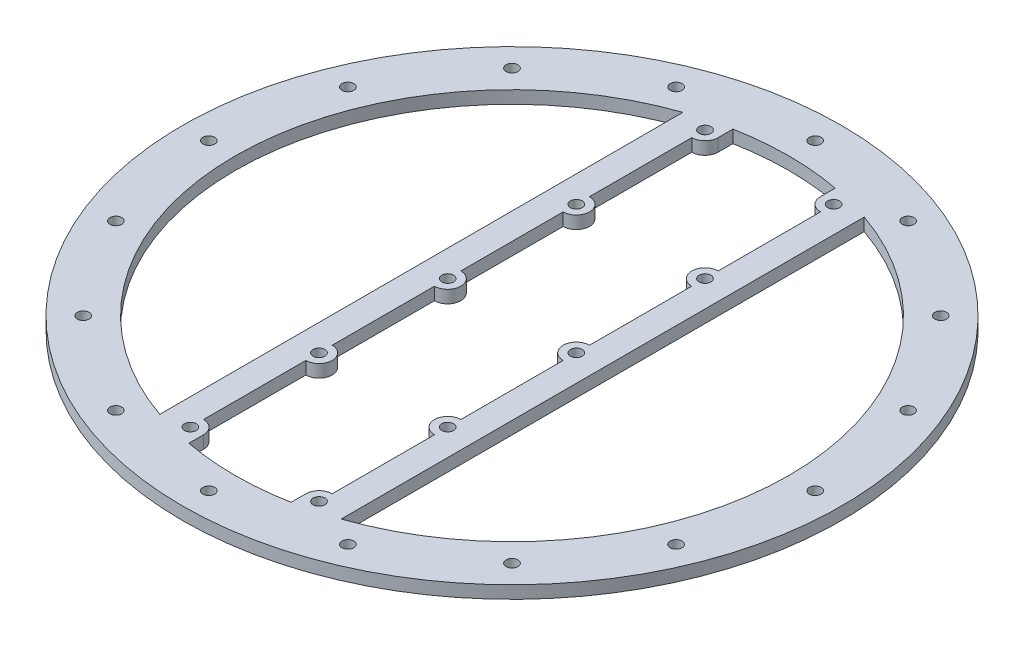
from build123d import *

# Parameters (mm, degrees)
SKETCH1_R           = 79.375
SKETCH1_R_2         = 66.675
SKETCH1_R_3         = 1.4224
BOSS_EXTRUDE1_DEPTH = 3.048
SKETCH2_R           = 1.4224
BOSS_EXTRUDE2_DEPTH = 3.048


with BuildPart() as part:
    # Sketch1 → Boss-Extrude1 (new body)
    with BuildSketch(Plane(origin=(0, 0, 0), x_dir=(1, 0, 0), z_dir=(0, 1, 0))):
        with Locations(Location((0, 0, 0), (0, 0, 90))):
            Circle(SKETCH1_R)
        with Locations(Location((0, 0, 0), (0, 0, 90))):
            Circle(SKETCH1_R_2, mode=Mode.SUBTRACT)
        with Locations(Location((0, 73.025, 0), (0, 0, 90))):
            Circle(SKETCH1_R_3, mode=Mode.SUBTRACT)
        with Locations(Location((27.945457648, 67.466302862, 0), (0, 0, 90))):
            Circle(SKETCH1_R_3, mode=Mode.SUBTRACT)
        with Locations(Location((51.636472696, 51.636472696, 0), (0, 0, 90))):
            Circle(SKETCH1_R_3, mode=Mode.SUBTRACT)
        with Locations(Location((67.466302862, 27.945457648, 0), (0, 0, 90))):
            Circle(SKETCH1_R_3, mode=Mode.SUBTRACT)
        with Locations(Location((73.025, 0, 0), (0, 0, 90))):
            Circle(SKETCH1_R_3, mode=Mode.SUBTRACT)
        with Locations(Location((67.466302862, -27.945457648, 0), (0, 0, 90))):
            Circle(SKETCH1_R_3, mode=Mode.SUBTRACT)
        with Locations(Location((51.636472696, -51.636472696, 0), (0, 0, 90))):
            Circle(SKETCH1_R_3, mode=Mode.SUBTRACT)
        with Locations(Location((27.945457648, -67.466302862, 0), (0, 0, 90))):
            Circle(SKETCH1_R_3, mode=Mode.SUBTRACT)
        with Locations(Location((0, -73.025, 0), (0, 0, 90))):
            Circle(SKETCH1_R_3, mode=Mode.SUBTRACT)
        with Locations(Location((-27.945457648, -67.466302862, 0), (0, 0, 90))):
            Circle(SKETCH1_R_3, mode=Mode.SUBTRACT)
        with Locations(Location((-51.636472696, -51.636472696, 0), (0, 0, 90))):
            Circle(SKETCH1_R_3, mode=Mode.SUBTRACT)
        with Locations(Location((-67.466302862, -27.945457648, 0), (0, 0, 90))):
            Circle(SKETCH1_R_3, mode=Mode.SUBTRACT)
        with Locations(Location((-73.025, 0, 0), (0, 0, 90))):
            Circle(SKETCH1_R_3, mode=Mode.SUBTRACT)
        with Locations(Location((-67.466302862, 27.945457648, 0), (0, 0, 90))):
            Circle(SKETCH1_R_3, mode=Mode.SUBTRACT)
        with Locations(Location((-51.636472696, 51.636472696, 0), (0, 0, 90))):
            Circle(SKETCH1_R_3, mode=Mode.SUBTRACT)
        with Locations(Location((-27.945457648, 67.466302862, 0), (0, 0, 90))):
            Circle(SKETCH1_R_3, mode=Mode.SUBTRACT)
    extrude(amount=BOSS_EXTRUDE1_DEPTH)

    # Sketch2 → Boss-Extrude2 (add)
    with BuildSketch(Plane(origin=(0, 3.048, 0), x_dir=(1, 0, 0), z_dir=(0, 1, 0))):
        with BuildLine():
            Line((-15.494, 3.175), (-15.494, 27.813))
            ThreePointArc((-15.494, 27.813), (-12.319, 30.988), (-15.494, 34.163))
            Line((-15.494, 34.163), (-15.494, 58.801))
            ThreePointArc((-15.494, 58.801), (-13.24893597, 59.73093597), (-12.319, 61.976))
            Line((-12.319, 61.976), (-12.319, 65.527077334))
            ThreePointArc((-12.319, 65.527077334), (-17.128346163, 64.437375666), (-21.844, 62.995200524))
            Line((-21.844, 62.995200524), (-21.844, -62.995200524))
            ThreePointArc((-21.844, -62.995200524), (-17.128346163, -64.437375666), (-12.319, -65.527077334))
            Line((-12.319, -65.527077334), (-12.319, -61.976))
            ThreePointArc((-12.319, -61.976), (-13.24893597, -59.73093597), (-15.494, -58.801))
            Line((-15.494, -58.801), (-15.494, -34.163))
            ThreePointArc((-15.494, -34.163), (-12.319, -30.988), (-15.494, -27.813))
            Line((-15.494, -27.813), (-15.494, -3.175))
            ThreePointArc((-15.494, -3.175), (-12.319, 0), (-15.494, 3.175))
        make_face()
        with Locations(Location((-15.494, 30.988, 0), (0, 0, 270))):
            Circle(SKETCH2_R, mode=Mode.SUBTRACT)
        with Locations(Location((-15.494, 0, 0), (0, 0, 270))):
            Circle(SKETCH2_R, mode=Mode.SUBTRACT)
        with Locations(Location((-15.494, 61.976, 0), (0, 0, 270))):
            Circle(SKETCH2_R, mode=Mode.SUBTRACT)
        with Locations(Location((-15.494, -30.988, 0), (0, 0, 270))):
            Circle(SKETCH2_R, mode=Mode.SUBTRACT)
        with Locations(Location((-15.494, -61.976, 0), (0, 0, 270))):
            Circle(SKETCH2_R, mode=Mode.SUBTRACT)
        with BuildLine():
            Line((12.319, 65.527077334), (12.319, 61.976))
            ThreePointArc((12.319, 61.976), (13.24893597, 59.73093597), (15.494, 58.801))
            Line((15.494, 58.801), (15.494, 34.163))
            ThreePointArc((15.494, 34.163), (12.319, 30.988), (15.494, 27.813))
            Line((15.494, 27.813), (15.494, 3.175))
            ThreePointArc((15.494, 3.175), (12.319, 0), (15.494, -3.175))
            Line((15.494, -3.175), (15.494, -27.813))
            ThreePointArc((15.494, -27.813), (12.319, -30.988), (15.494, -34.163))
            Line((15.494, -34.163), (15.494, -58.801))
            ThreePointArc((15.494, -58.801), (13.24893597, -59.73093597), (12.319, -61.976))
            Line((12.319, -61.976), (12.319, -65.527077334))
            ThreePointArc((12.319, -65.527077334), (17.128346163, -64.437375666), (21.844, -62.995200524))
            Line((21.844, -62.995200524), (21.844, 62.995200524))
            ThreePointArc((21.844, 62.995200524), (17.128346163, 64.437375666), (12.319, 65.527077334))
        make_face()
        with Locations(Location((15.494, 61.976, 0), (0, 0, 270))):
            Circle(SKETCH2_R, mode=Mode.SUBTRACT)
        with Locations(Location((15.494, 30.988, 0), (0, 0, 270))):
            Circle(SKETCH2_R, mode=Mode.SUBTRACT)
        with Locations(Location((15.494, -61.976, 0), (0, 0, 270))):
            Circle(SKETCH2_R, mode=Mode.SUBTRACT)
        with Locations(Location((15.494, 0, 0), (0, 0, 270))):
            Circle(SKETCH2_R, mode=Mode.SUBTRACT)
        with Locations(Location((15.494, -30.988, 0), (0, 0, 270))):
            Circle(SKETCH2_R, mode=Mode.SUBTRACT)
    extrude(amount=-BOSS_EXTRUDE2_DEPTH)


solid = part.part
